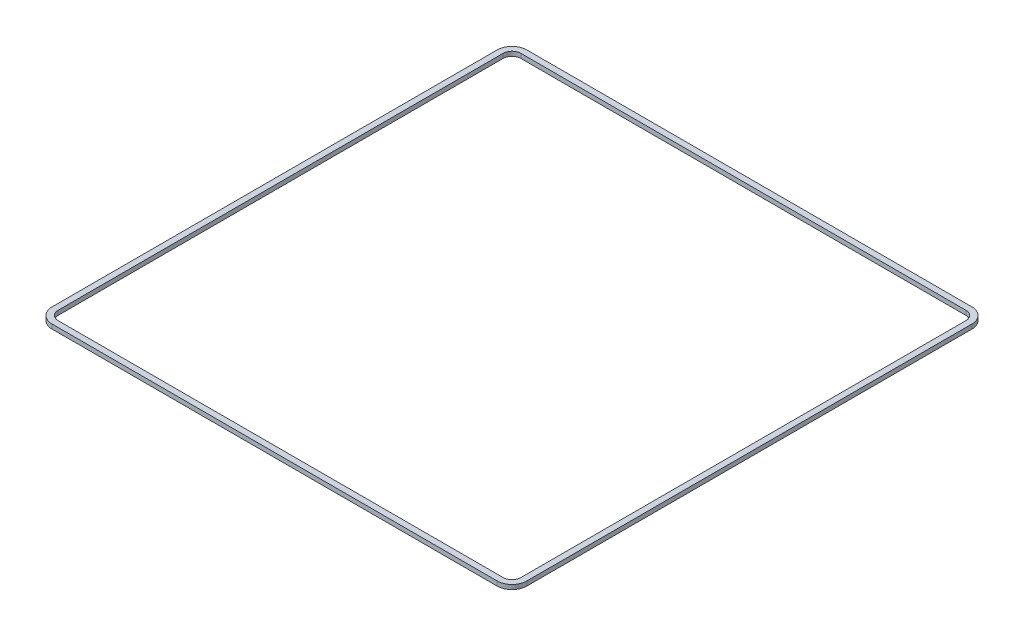
from build123d import *

# Parameters (mm, degrees)
SKETCH1_W           = 320
SKETCH1_H           = 320
SKETCH1_R           = 2.25
SKETCH1_R_2         = 15
SKETCH1_W_2         = 248
SKETCH1_H_2         = 112
BOSS_EXTRUDE1_DEPTH = 3
FILLET1_R           = 10
SKETCH2_R           = 2.25
SKETCH2_R_2         = 15
SKETCH2_W           = 248
SKETCH2_H           = 112
CUT_EXTRUDE1_DEPTH  = 10


with BuildPart() as part:
    # Sketch1 → Boss-Extrude1 (new body)
    with BuildSketch(Plane(origin=(0, 0, 0), x_dir=(1, 0, 0), z_dir=(0, 1, 0))):
        with Locations((45.2, -56.43)):
            Rectangle(SKETCH1_W, SKETCH1_H)
        with Locations((-36.05, -70.43)):
            Circle(SKETCH1_R, mode=Mode.SUBTRACT)
        with Locations((126.45, -70.43)):
            Circle(SKETCH1_R, mode=Mode.SUBTRACT)
        with Locations((128.7, -200.43)):
            Circle(SKETCH1_R, mode=Mode.SUBTRACT)
        with Locations((-33.8, -200.43)):
            Circle(SKETCH1_R, mode=Mode.SUBTRACT)
        with Locations((45.2, -135.43)):
            Circle(SKETCH1_R_2, mode=Mode.SUBTRACT)
        with Locations((45.2, 41.57)):
            Rectangle(SKETCH1_W_2, SKETCH1_H_2, mode=Mode.SUBTRACT)
    extrude(amount=BOSS_EXTRUDE1_DEPTH)

    # Fillet1
    fillet1_edges = [part.edges().sort_by_distance(p)[0] for p in [
        (205.2, 1.5, 216.43),
        (-114.8, 1.5, 216.43),
        (-114.8, 1.5, -103.57),
        (205.2, 1.5, -103.57),
    ]]
    fillet(fillet1_edges, radius=FILLET1_R)

    # Sketch2 → Cut-Extrude1 (cut)
    with BuildSketch(Plane(origin=(0, 3, 0), x_dir=(1, 0, 0), z_dir=(0, 1, 0))):
        with BuildLine():
            Line((-104.8, 99.57), (195.2, 99.57))
            ThreePointArc((195.2, 99.57), (199.442640687, 97.812640687), (201.2, 93.57))
            Line((201.2, 93.57), (201.2, -206.43))
            ThreePointArc((201.2, -206.43), (199.442640687, -210.672640687), (195.2, -212.43))
            Line((195.2, -212.43), (-104.8, -212.43))
            ThreePointArc((-104.8, -212.43), (-109.042640687, -210.672640687), (-110.8, -206.43))
            Line((-110.8, -206.43), (-110.8, 93.57))
            ThreePointArc((-110.8, 93.57), (-109.042640687, 97.812640687), (-104.8, 99.57))
        make_face()
        with Locations((-33.8, -200.43)):
            Circle(SKETCH2_R, mode=Mode.SUBTRACT)
        with Locations((126.45, -70.43)):
            Circle(SKETCH2_R, mode=Mode.SUBTRACT)
        with Locations((-36.05, -70.43)):
            Circle(SKETCH2_R, mode=Mode.SUBTRACT)
        with Locations((128.7, -200.43)):
            Circle(SKETCH2_R, mode=Mode.SUBTRACT)
        with Locations((45.2, -135.43)):
            Circle(SKETCH2_R_2, mode=Mode.SUBTRACT)
        with Locations((45.2, 41.57)):
            Rectangle(SKETCH2_W, SKETCH2_H, mode=Mode.SUBTRACT)
    extrude(amount=-CUT_EXTRUDE1_DEPTH, mode=Mode.SUBTRACT)


solid = part.part
